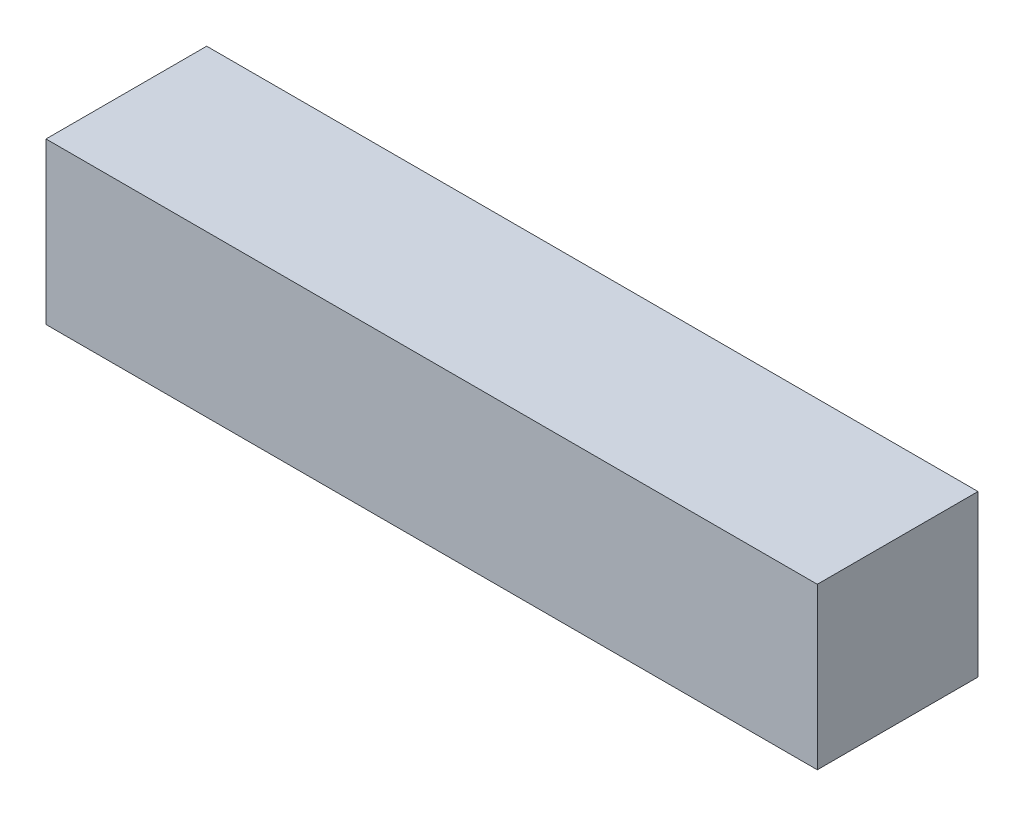
from build123d import *

# Parameters (mm, degrees)
SKETCH1_W           = 1200
SKETCH1_H           = 250
BOSS_EXTRUDE1_DEPTH = 125


with BuildPart() as part:
    # Sketch1 → Boss-Extrude1 (new, symmetric)
    with BuildSketch(Plane.XY):
        with Locations((0, 125)):
            Rectangle(SKETCH1_W, SKETCH1_H)
    extrude(amount=BOSS_EXTRUDE1_DEPTH, both=True)


solid = part.part
